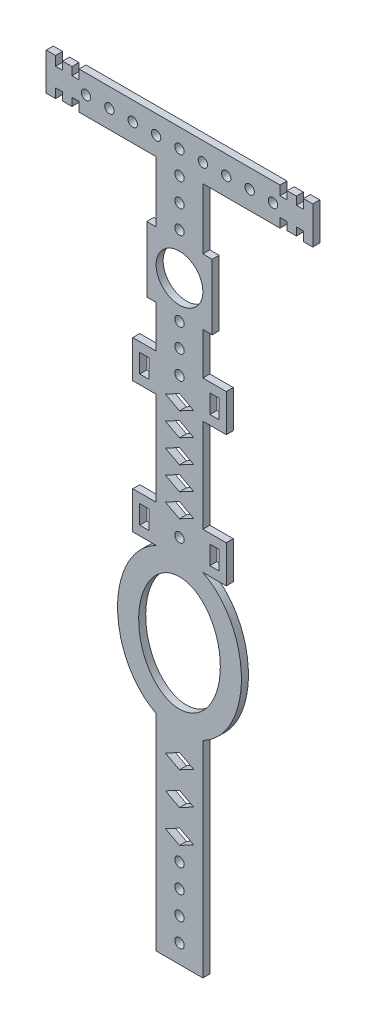
from build123d import *

# Parameters (mm, degrees)
SKETCH_1_W      = 2
SKETCH_1_H      = 4
SKETCH_1_R      = 1
SKETCH_1_R_2    = 5
EXTRUDE_1_DEPTH = 1.5


with BuildPart() as part:
    # 草图1 → 凸台-拉伸1 (new body)
    with BuildSketch(Plane.XY):
        with BuildLine():
            Line((21.499281064, 30), (-21.499281064, 30))
            Line((-21.499281064, 30), (-21.499281064, 28))
            Line((-21.499281064, 28), (-22.999281064, 28))
            Line((-22.999281064, 28), (-22.999281064, 29.7))
            Line((-22.999281064, 29.7), (-24.999281064, 29.7))
            Line((-24.999281064, 29.7), (-24.999281064, 28))
            Line((-24.999281064, 28), (-26.499281064, 28))
            Line((-26.499281064, 28), (-26.499281064, 30))
            Line((-26.499281064, 30), (-28.499281064, 30))
            Line((-28.499281064, 30), (-28.499281064, 22))
            Line((-28.499281064, 22), (-26.499281064, 22))
            Line((-26.499281064, 22), (-26.499281064, 24))
            Line((-26.499281064, 24), (-24.999281064, 24))
            Line((-24.999281064, 24), (-24.999281064, 22.3))
            Line((-24.999281064, 22.3), (-22.999281064, 22.3))
            Line((-22.999281064, 22.3), (-22.999281064, 24))
            Line((-22.999281064, 24), (-21.499281064, 24))
            Line((-21.499281064, 24), (-21.499281064, 22))
            Line((-21.499281064, 22), (-5, 22))
            Line((-5, 22), (-5, 9))
            Line((-5, 9), (-7, 9))
            Line((-7, 9), (-7, -5))
            Line((-7, -5), (-5, -5))
            Line((-5, -5), (-5, -14))
            Line((-5, -14), (-10, -14))
            Line((-10, -14), (-10, -22))
            Line((-10, -22), (-5, -22))
            Line((-5, -22), (-5, -42))
            Line((-5, -42), (-10, -42))
            Line((-10, -42), (-10, -50))
            Line((-10, -50), (-5, -50))
            add(Edge.make_bspline(
                [(-5, -50), (-5.206631572, -50.1046163), (-7.122538881, -51.146340962), (-10.136236083, -54.053937604), (-12.460991296, -59.031081614), (-13.257864896, -63.527529667), (-13.257864896, -67.592056821), (-12.460991296, -72.088504874), (-10.136236082, -77.065648884), (-7.122538881, -79.973245525), (-5.206631571, -81.014970188), (-5, -81.119586487)],
                knots=[3.487673016, 3.487673016, 3.487673016, 3.487673016, 3.534291735, 3.926990817, 4.319689899, 4.61421421, 4.810563751, 5.105088062, 5.497787144, 5.890486225, 5.937104944, 5.937104944, 5.937104944, 5.937104944], degree=3))
            Line((-5, -81.119586487), (-5, -125.119586487))
            Line((-5, -125.119586487), (5, -125.119586487))
            Line((5, -125.119586487), (5, -81.119586487))
            add(Edge.make_bspline(
                [(5, -81.119586487), (5.206631572, -81.014970188), (7.122538881, -79.973245525), (10.136236083, -77.065648883), (12.460991296, -72.088504873), (13.257864896, -67.592056821), (13.257864896, -63.527529666), (12.460991296, -59.031081614), (10.136236082, -54.053937604), (7.122538881, -51.146340962), (5.206631571, -50.1046163), (5, -50)],
                knots=[6.62926567, 6.62926567, 6.62926567, 6.62926567, 6.675884389, 7.068583471, 7.461282552, 7.755806864, 7.952156404, 8.246680716, 8.639379797, 9.032078879, 9.078697598, 9.078697598, 9.078697598, 9.078697598], degree=3))
            Line((5, -50), (10, -50))
            Line((10, -50), (10, -42))
            Line((10, -42), (5, -42))
            Line((5, -42), (5, -22))
            Line((5, -22), (10, -22))
            Line((10, -22), (10, -14))
            Line((10, -14), (5, -14))
            Line((5, -14), (5, -5))
            Line((5, -5), (7, -5))
            Line((7, -5), (7, 9))
            Line((7, 9), (5, 9))
            Line((5, 9), (5, 22))
            Line((5, 22), (21.499281064, 22))
            Line((21.499281064, 22), (21.499281064, 24))
            Line((21.499281064, 24), (22.999281064, 24))
            Line((22.999281064, 24), (22.999281064, 22.3))
            Line((22.999281064, 22.3), (24.999281064, 22.3))
            Line((24.999281064, 22.3), (24.999281064, 24))
            Line((24.999281064, 24), (26.499281064, 24))
            Line((26.499281064, 24), (26.499281064, 22))
            Line((26.499281064, 22), (28.499281064, 22))
            Line((28.499281064, 22), (28.499281064, 30))
            Line((28.499281064, 30), (26.499281064, 30))
            Line((26.499281064, 30), (26.499281064, 28))
            Line((26.499281064, 28), (24.999281064, 28))
            Line((24.999281064, 28), (24.999281064, 29.7))
            Line((24.999281064, 29.7), (22.999281064, 29.7))
            Line((22.999281064, 29.7), (22.999281064, 28))
            Line((22.999281064, 28), (21.499281064, 28))
            Line((21.499281064, 28), (21.499281064, 30))
        make_face()
        with Locations((-7.5, -46)):
            Rectangle(SKETCH_1_W, SKETCH_1_H, mode=Mode.SUBTRACT)
        with Locations((0, -46)):
            Circle(SKETCH_1_R, mode=Mode.SUBTRACT)
        Polygon((-0.012070401, -39.375169449), (2.987929599, -40.978587718), (-0.012070401, -42.582005987), (-3.012070401, -40.978587718), align=None, mode=Mode.SUBTRACT)
        Polygon((-0.012070401, -34.375169449), (2.987929599, -35.978587718), (-0.012070401, -37.582005987), (-3.012070401, -35.978587718), align=None, mode=Mode.SUBTRACT)
        Polygon((-0.012070401, -29.375169449), (2.987929599, -30.978587718), (-0.012070401, -32.582005987), (-3.012070401, -30.978587718), align=None, mode=Mode.SUBTRACT)
        with Locations((-7.5, -18)):
            Rectangle(SKETCH_1_W, SKETCH_1_H, mode=Mode.SUBTRACT)
        Polygon((-0.012070401, -24.375169449), (2.987929599, -25.978587718), (-0.012070401, -27.582005987), (-3.012070401, -25.978587718), align=None, mode=Mode.SUBTRACT)
        Polygon((-0.012070401, -19.375169449), (2.987929599, -20.978587718), (-0.012070401, -22.582005987), (-3.012070401, -20.978587718), align=None, mode=Mode.SUBTRACT)
        with Locations((0, -16)):
            Circle(SKETCH_1_R, mode=Mode.SUBTRACT)
        with Locations((0, -11)):
            Circle(SKETCH_1_R, mode=Mode.SUBTRACT)
        with Locations((-20, 25.95138361)):
            Circle(SKETCH_1_R, mode=Mode.SUBTRACT)
        with Locations((-15, 25.95138361)):
            Circle(SKETCH_1_R, mode=Mode.SUBTRACT)
        with Locations((0, -6)):
            Circle(SKETCH_1_R, mode=Mode.SUBTRACT)
        with Locations((0, 2)):
            Circle(SKETCH_1_R_2, mode=Mode.SUBTRACT)
        with Locations((-10, 25.95138361)):
            Circle(SKETCH_1_R, mode=Mode.SUBTRACT)
        with Locations((-5, 25.95138361)):
            Circle(SKETCH_1_R, mode=Mode.SUBTRACT)
        with Locations((0, 25.95138361)):
            Circle(SKETCH_1_R, mode=Mode.SUBTRACT)
        with Locations((7.5, -46)):
            Rectangle(SKETCH_1_W, SKETCH_1_H, mode=Mode.SUBTRACT)
        with Locations((7.5, -18)):
            Rectangle(SKETCH_1_W, SKETCH_1_H, mode=Mode.SUBTRACT)
        with Locations((0, 10.95138361)):
            Circle(SKETCH_1_R, mode=Mode.SUBTRACT)
        with Locations((0, 15.95138361)):
            Circle(SKETCH_1_R, mode=Mode.SUBTRACT)
        with Locations((0, 20.95138361)):
            Circle(SKETCH_1_R, mode=Mode.SUBTRACT)
        with Locations((5, 25.95138361)):
            Circle(SKETCH_1_R, mode=Mode.SUBTRACT)
        with Locations((10, 25.95138361)):
            Circle(SKETCH_1_R, mode=Mode.SUBTRACT)
        with Locations((15, 25.95138361)):
            Circle(SKETCH_1_R, mode=Mode.SUBTRACT)
        with Locations((20, 25.95138361)):
            Circle(SKETCH_1_R, mode=Mode.SUBTRACT)
        with BuildLine():
            add(Edge.make_bspline(
                [(0, -77.82152984), (15.11674465, -77.82152984), (7.558372325, -59.428924948), (0, -41.036320056), (-7.558372325, -59.428924948), (-15.11674465, -77.82152984), (0, -77.82152984)],
                knots=[0, 0, 0, 2.094395102, 2.094395102, 4.188790205, 4.188790205, 6.283185307, 6.283185307, 6.283185307], degree=2, weights=[1, 0.5, 1, 0.5, 1, 0.5, 1]))
        make_face(mode=Mode.SUBTRACT)
        Polygon((3, -87.457928946), (0, -89.061347215), (-3, -87.457928946), (0, -85.854510677), align=None, mode=Mode.SUBTRACT)
        with Locations((0, -121.119586487)):
            Circle(SKETCH_1_R, mode=Mode.SUBTRACT)
        with Locations((0, -116.119586487)):
            Circle(SKETCH_1_R, mode=Mode.SUBTRACT)
        with Locations((0, -111.119586487)):
            Circle(SKETCH_1_R, mode=Mode.SUBTRACT)
        with Locations((0, -106.119586487)):
            Circle(SKETCH_1_R, mode=Mode.SUBTRACT)
        Polygon((0, -99.854510677), (3, -101.457928946), (0, -103.061347215), (-3, -101.457928946), align=None, mode=Mode.SUBTRACT)
        Polygon((0, -92.854510677), (3, -94.457928946), (0, -96.061347215), (-3, -94.457928946), align=None, mode=Mode.SUBTRACT)
    extrude(amount=EXTRUDE_1_DEPTH)


solid = part.part
